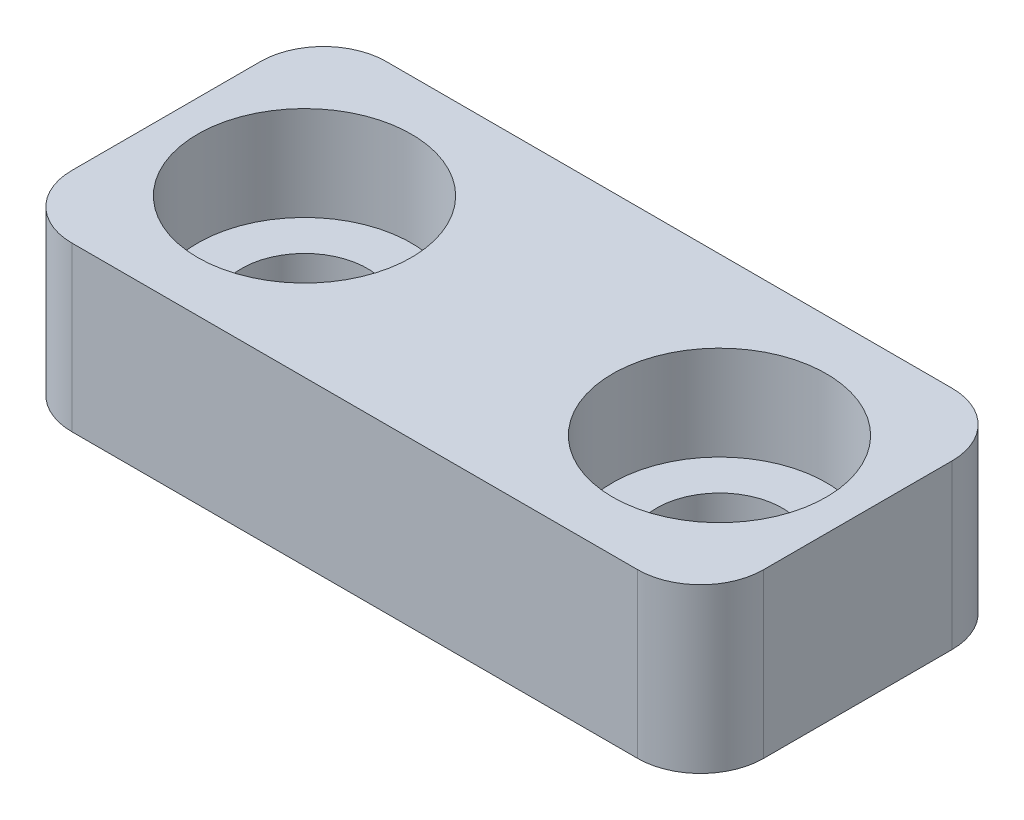
from build123d import *

# Parameters (mm, degrees)
SKETCH1_W           = 11
SKETCH1_H           = 5
SKETCH1_R           = 1
BOSS_EXTRUDE1_DEPTH = 2.6
SKETCH2_R           = 1.7
CUT_EXTRUDE1_DEPTH  = 1.5
FILLET1_R           = 1


with BuildPart() as part:
    # Sketch1 → Boss-Extrude1 (new body)
    with BuildSketch(Plane(origin=(0, 0, 0), x_dir=(1, 0, 0), z_dir=(0, 1, 0))):
        Rectangle(SKETCH1_W, SKETCH1_H)
        with Locations((-3.3, 0)):
            Circle(SKETCH1_R, mode=Mode.SUBTRACT)
        with Locations((3.3, 0)):
            Circle(SKETCH1_R, mode=Mode.SUBTRACT)
    extrude(amount=BOSS_EXTRUDE1_DEPTH)

    # Sketch2 → Cut-Extrude1 (cut)
    with BuildSketch(Plane(origin=(0, 2.6, 0), x_dir=(1, 0, 0), z_dir=(0, 1, 0))):
        with Locations((-3.3, 0)):
            Circle(SKETCH2_R)
        with Locations((3.3, 0)):
            Circle(SKETCH2_R)
    extrude(amount=-CUT_EXTRUDE1_DEPTH, mode=Mode.SUBTRACT)

    # Fillet1
    fillet1_edges = [part.edges().sort_by_distance(p)[0] for p in [
        (5.5, 1.3, 2.5),
        (-5.5, 1.3, 2.5),
        (-5.5, 1.3, -2.5),
        (5.5, 1.3, -2.5),
    ]]
    fillet(fillet1_edges, radius=FILLET1_R)


solid = part.part
